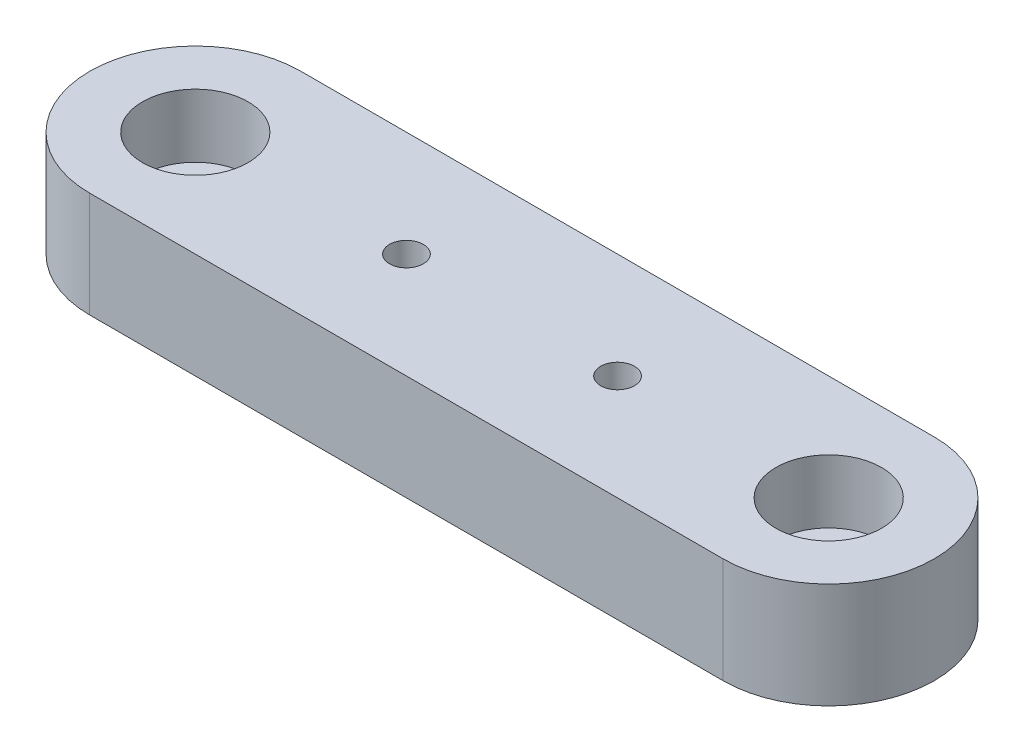
from build123d import *

# Parameters (mm, degrees)
SKETCH1_R                                      = 10
SKETCH1_R_2                                    = 3
SKETCH1_R_3                                    = 1.6
BOSS_EXTRUDE1_DEPTH                            = 10
SKETCH2_R                                      = 5
CUT_EXTRUDE1_DEPTH                             = 6
CSK_FOR_M3_FLAT_HEAD_MACHINE_SCREW1_AT_2_COUNT = 2
CSK_FOR_M3_FLAT_HEAD_MACHINE_SCREW1_AT_2_PITCH = 20


with BuildPart() as part:
    # Sketch1 → Boss-Extrude1 (new body)
    with BuildSketch(Plane(origin=(0, 0, 0), x_dir=(1, 0, 0), z_dir=(0, 1, 0))):
        with Locations((-30, 0)):
            Circle(SKETCH1_R)
        with Locations((-30, 0)):
            Circle(SKETCH1_R_2, mode=Mode.SUBTRACT)
        with BuildLine():
            Line((29.999999936, 10), (-30, 10))
            ThreePointArc((-30, 10), (-22.928932188, 7.071067812), (-20, 0))
            ThreePointArc((-20, 0), (-22.928932188, -7.071067812), (-30, -10))
            Line((-30, -10), (30, -10))
            ThreePointArc((30, -10), (20, -3.2e-08), (29.999999936, 10))
        make_face()
        with Locations((-10, 0)):
            Circle(SKETCH1_R_3, mode=Mode.SUBTRACT)
        with Locations((10, 0)):
            Circle(SKETCH1_R_3, mode=Mode.SUBTRACT)
        with Locations((30, 0)):
            Circle(SKETCH1_R)
        with Locations((30, 0)):
            Circle(SKETCH1_R_2, mode=Mode.SUBTRACT)
    extrude(amount=BOSS_EXTRUDE1_DEPTH)

    # Sketch2 → Cut-Extrude1 (cut)
    with BuildSketch(Plane(origin=(0, 10, 0), x_dir=(1, 0, 0), z_dir=(0, 1, 0))):
        with Locations((-30, 0)):
            Circle(SKETCH2_R)
        with Locations((30, 0)):
            Circle(SKETCH2_R)
    extrude(amount=-CUT_EXTRUDE1_DEPTH, mode=Mode.SUBTRACT)

    # Sketch4 → CSK for M3 Flat Head Machine Screw1 (revolve, cut)
    with BuildSketch(Plane(origin=(-10, 0, 0), x_dir=(0, 0, -1), z_dir=(1, 0, 0))):
        Polygon((0, 0), (0, 10), (1.5, 10), (1.5, 1.8), (3, 0.3), (3, 0), align=None)
    csk_for_m3_flat_head_machine_screw1 = revolve(axis=Axis((-10, -6.35, 0), (0, 1, 0)), mode=Mode.SUBTRACT)

    # CSK for M3 Flat Head Machine Screw1 at 2: CSK for M3 Flat Head Machine Screw1 ×2
    with Locations(*[(i * CSK_FOR_M3_FLAT_HEAD_MACHINE_SCREW1_AT_2_PITCH, 0, 0) for i in range(1, CSK_FOR_M3_FLAT_HEAD_MACHINE_SCREW1_AT_2_COUNT)]):
        add(csk_for_m3_flat_head_machine_screw1, mode=Mode.SUBTRACT)


solid = part.part
